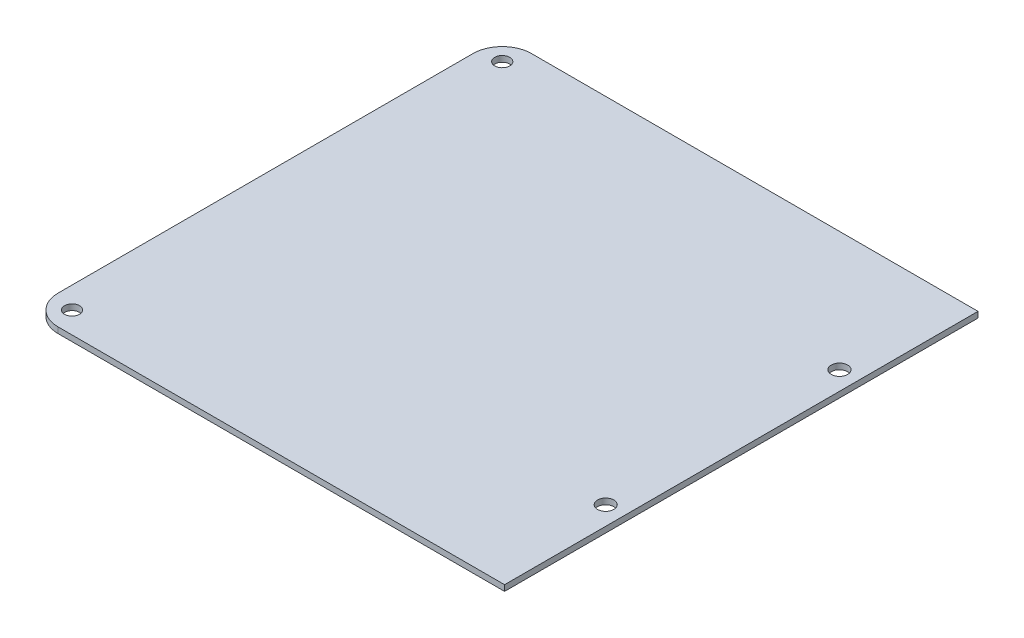
from build123d import *

# Parameters (mm, degrees)
SKETCH1_W                 = 99.695
SKETCH1_H                 = 102.87
BOSS_EXTRUDE1_DEPTH       = 2.54
FILLET2_R                 = 6.35
F_4_CLEARANCE_HOLE1_D     = 3.2639
F_4_CLEARANCE_HOLE1_DEPTH = 4.953
F_4_CLEARANCE_HOLE1_TIP   = 0.980574487
SKETCH5_W                 = 102.87
SKETCH5_H                 = 1.27
CUT_EXTRUDE1_DEPTH        = 4.445
SKETCH6_W                 = 102.87
SKETCH6_H                 = 1.27
BOSS_EXTRUDE3_DEPTH       = 3.683
F_4_CLEARANCE_HOLE2_D     = 3.556
F_4_CLEARANCE_HOLE2_DEPTH = 7.5946
F_4_CLEARANCE_HOLE2_TIP   = 1.068330181
CUT_EXTRUDE2_DEPTH        = 1.27
CUT_EXTRUDE3_DEPTH        = 1.74


with BuildPart() as part:
    # Sketch1 → Boss-Extrude1 (new body)
    with BuildSketch(Plane(origin=(0, 0, 0), x_dir=(1, 0, 0), z_dir=(0, 1, 0))):
        Rectangle(SKETCH1_W, SKETCH1_H)
    extrude(amount=BOSS_EXTRUDE1_DEPTH)

    # Fillet2
    fillet2_edges = [part.edges().sort_by_distance(p)[0] for p in [
        (-49.8475, 1.27, 51.435),
        (-49.8475, 1.27, -51.435),
    ]]
    fillet(fillet2_edges, radius=FILLET2_R)

    # #4 Clearance Hole1
    with Locations(Plane(origin=(0, 2.54, 0), x_dir=(1, 0, 0), z_dir=(0, 1, 0))):
        with Locations((-45.1485, 46.736), (-45.1485, -46.736)):
            Hole(F_4_CLEARANCE_HOLE1_D / 2, depth=F_4_CLEARANCE_HOLE1_DEPTH)
            with Locations((0, 0, -(F_4_CLEARANCE_HOLE1_DEPTH + F_4_CLEARANCE_HOLE1_TIP / 2))):  # 118° drill point
                Cone(0, F_4_CLEARANCE_HOLE1_D / 2, F_4_CLEARANCE_HOLE1_TIP, mode=Mode.SUBTRACT)

    # Sketch5 → Cut-Extrude1 (cut)
    with BuildSketch(Plane(origin=(49.8475, 0, 0), x_dir=(0, 0, -1), z_dir=(1, 0, 0))):
        with Locations((0, 0.635)):
            Rectangle(SKETCH5_W, SKETCH5_H)
    extrude(amount=-CUT_EXTRUDE1_DEPTH, mode=Mode.SUBTRACT)

    # Sketch6 → Boss-Extrude3 (add)
    with BuildSketch(Plane(origin=(49.8475, 0, 0), x_dir=(0, 0, -1), z_dir=(1, 0, 0))):
        with Locations((0, 1.905)):
            Rectangle(SKETCH6_W, SKETCH6_H)
    extrude(amount=BOSS_EXTRUDE3_DEPTH)

    # #4 Clearance Hole2
    with Locations(Plane(origin=(0, 2.54, 0), x_dir=(1, 0, 0), z_dir=(0, 1, 0))):
        with Locations((49.4665, 25.4), (49.4665, -25.4)):
            Hole(F_4_CLEARANCE_HOLE2_D / 2, depth=F_4_CLEARANCE_HOLE2_DEPTH)
            with Locations((0, 0, -(F_4_CLEARANCE_HOLE2_DEPTH + F_4_CLEARANCE_HOLE2_TIP / 2))):  # 118° drill point
                Cone(0, F_4_CLEARANCE_HOLE2_D / 2, F_4_CLEARANCE_HOLE2_TIP, mode=Mode.SUBTRACT)

    # Sketch11 → Cut-Extrude2 (cut)
    with BuildSketch(Plane.XZ):
        with BuildLine():
            Line((-46.0375, -43.434), (-46.0375, 43.434))
            Line((-46.0375, 43.434), (-43.1165, 43.434))
            ThreePointArc((-43.1165, 43.434), (-42.218474388, 43.805974388), (-41.8465, 44.704))
            Line((-41.8465, 44.704), (-41.8465, 47.625))
            Line((-41.8465, 47.625), (45.4025, 47.625))
            Line((45.4025, 47.625), (45.4025, 51.435))
            Line((45.4025, 51.435), (-43.4975, 51.435))
            ThreePointArc((-43.4975, 51.435), (-47.987628061, 49.575128061), (-49.8475, 45.085))
            Line((-49.8475, 45.085), (-49.8475, -45.085))
            ThreePointArc((-49.8475, -45.085), (-47.987628061, -49.575128061), (-43.4975, -51.435))
            Line((-43.4975, -51.435), (45.4025, -51.435))
            Line((45.4025, -51.435), (45.4025, -47.625))
            Line((45.4025, -47.625), (-41.8465, -47.625))
            Line((-41.8465, -47.625), (-41.8465, -44.704))
            ThreePointArc((-41.8465, -44.704), (-42.218474388, -43.805974388), (-43.1165, -43.434))
            Line((-43.1165, -43.434), (-46.0375, -43.434))
        make_face()
    extrude(amount=-CUT_EXTRUDE2_DEPTH, mode=Mode.SUBTRACT)

    # Sketch12 → Cut-Extrude3 (cut)
    with BuildSketch(Plane.XZ):
        with BuildLine():
            Line((-27.834166667, -41.275), (-39.6875, -22.225))
            Line((-39.6875, -22.225), (-39.6875, -37.899122411))
            ThreePointArc((-39.6875, -37.899122411), (-37.728346327, -39.315846327), (-36.311622411, -41.275))
            Line((-36.311622411, -41.275), (-27.834166667, -41.275))
        make_face()
        Polygon((-14.710833333, -22.225), (-38.4175, -22.225), (-26.564166667, -41.275), align=None)
        Polygon((-13.440833333, -22.225), (-25.294166667, -41.275), (-1.5875, -41.275), align=None)
        Polygon((11.535833333, -22.225), (-12.170833333, -22.225), (-0.3175, -41.275), align=None)
        Polygon((12.805833333, -22.225), (0.9525, -41.275), (24.659166667, -41.275), align=None)
        Polygon((37.7825, -22.225), (14.075833333, -22.225), (25.929166667, -41.275), align=None)
        Polygon((39.0525, -41.275), (39.0525, -22.225), (27.199166667, -41.275), align=None)
        Polygon((-39.6875, -1.905), (-39.6875, -20.955), (-27.834166667, -1.905), align=None)
        Polygon((-26.564166667, -1.905), (-38.4175, -20.955), (-14.710833333, -20.955), align=None)
        Polygon((-25.294166667, -1.905), (-13.440833333, -20.955), (-1.5875, -1.905), align=None)
        Polygon((-0.3175, -1.905), (-12.170833333, -20.955), (11.535833333, -20.955), align=None)
        Polygon((0.9525, -1.905), (12.805833333, -20.955), (24.659166667, -1.905), align=None)
        Polygon((14.075833333, -20.955), (37.7825, -20.955), (25.929166667, -1.905), align=None)
        Polygon((39.0525, -20.955), (39.0525, -1.905), (27.199166667, -1.905), align=None)
    cut_extrude3 = extrude(amount=-CUT_EXTRUDE3_DEPTH, mode=Mode.SUBTRACT)

    # Mirror1: Cut-Extrude3 across plane
    add(cut_extrude3.mirror(Plane.XY), mode=Mode.SUBTRACT)


solid = part.part
